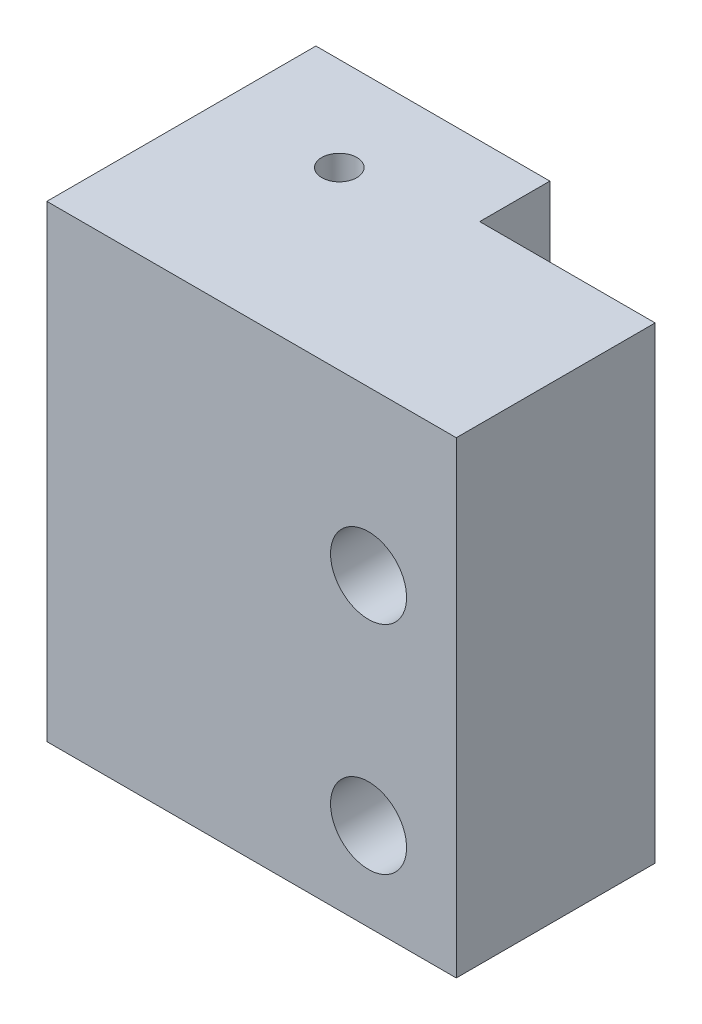
from build123d import *

# Parameters (mm, degrees)
BOSS_EXTRUDE2_DEPTH = 40
SKETCH3_R           = 4.05
CUT_EXTRUDE1_DEPTH  = 35
CUT_EXTRUDE2_REACH  = 19
SKETCH4_R           = 3.25
SKETCH6_R           = 1.5
CUT_EXTRUDE3_DEPTH  = 10


with BuildPart() as part:
    # Sketch1 → Boss-Extrude2 (new body)
    with BuildSketch(Plane(origin=(0, 0, 0), x_dir=(1, 0, 0), z_dir=(0, 1, 0))):
        Polygon((-10, -5.257459708), (-10, 0.742540292), (10, 0.742540292), (10, -5.257459708), (25, -5.257459708), (25, -22.257459708), (-10, -22.257459708), align=None)
    extrude(amount=BOSS_EXTRUDE2_DEPTH)

    # Sketch3 → Cut-Extrude1 (cut)
    with BuildSketch(Plane.XZ):
        with Locations((0, 7.257459708)):
            Circle(SKETCH3_R)
    extrude(amount=-CUT_EXTRUDE1_DEPTH, mode=Mode.SUBTRACT)

    # Sketch4 → Cut-Extrude2 (cut, up to next)
    with BuildSketch(Plane(origin=(0, 0, 5.257459708), x_dir=(-1, 0, 0), z_dir=(0, 0, -1)), mode=Mode.PRIVATE) as cut_extrude2_sk1:
        with Locations((-17.5, 26.045770547)):
            Circle(SKETCH4_R)
    cut_extrude2_tool1 = extrude(cut_extrude2_sk1.sketch, amount=-CUT_EXTRUDE2_REACH, mode=Mode.PRIVATE) & part.part
    add(cut_extrude2_tool1.solids().sort_by_distance((17.5, 26.045771, 5.25746))[0], mode=Mode.SUBTRACT)
    # Sketch4 → Cut-Extrude2 (cut, up to next)
    with BuildSketch(Plane(origin=(0, 0, 5.257459708), x_dir=(-1, 0, 0), z_dir=(0, 0, -1)), mode=Mode.PRIVATE) as cut_extrude2_sk2:
        with Locations((-17.5, 7.535290978)):
            Circle(SKETCH4_R)
    cut_extrude2_tool2 = extrude(cut_extrude2_sk2.sketch, amount=-CUT_EXTRUDE2_REACH, mode=Mode.PRIVATE) & part.part
    add(cut_extrude2_tool2.solids().sort_by_distance((17.5, 7.535291, 5.25746))[0], mode=Mode.SUBTRACT)

    # Sketch6 → Cut-Extrude3 (cut)
    with BuildSketch(Plane.XZ.offset(-35)):
        with Locations((0, 7.257459708)):
            Circle(SKETCH6_R)
    extrude(amount=-CUT_EXTRUDE3_DEPTH, mode=Mode.SUBTRACT)


solid = part.part
